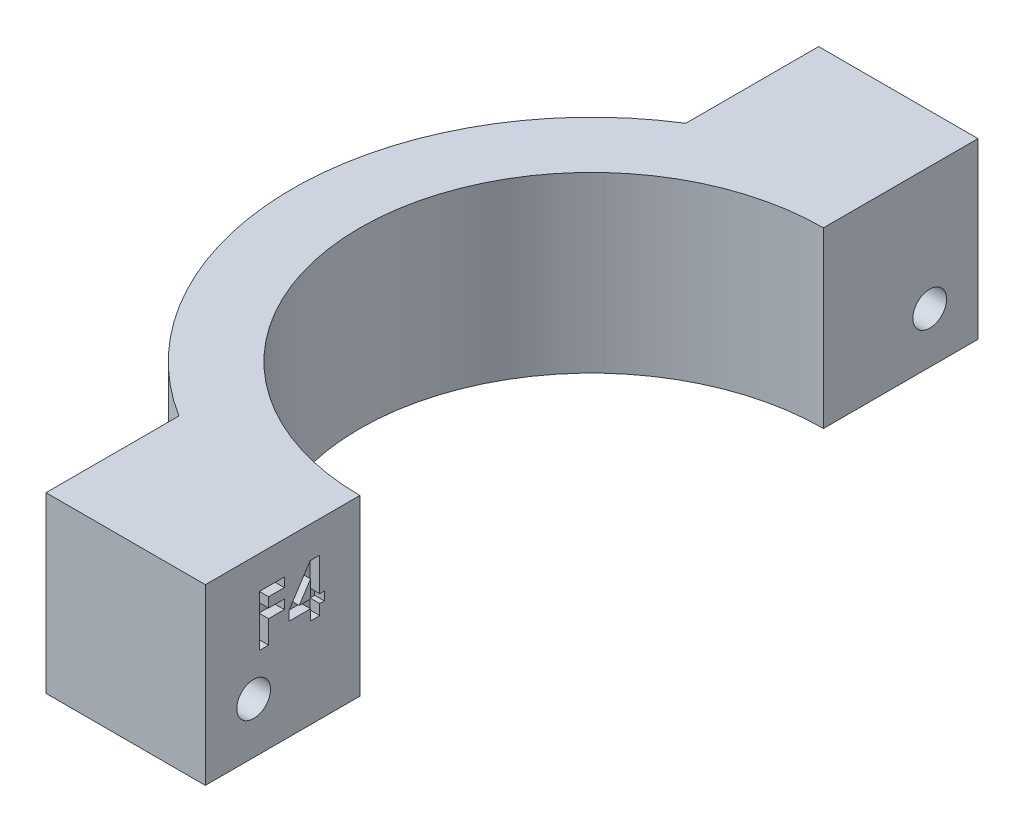
from build123d import *

# Parameters (mm, degrees)
BOSS_EXTRUDE1_DEPTH = 18
SKETCH2_R           = 1.75
CUT_EXTRUDE1_DEPTH  = 32
CUT_EXTRUDE2_DEPTH  = 1
CUT_EXTRUDE3_DEPTH  = 5


with BuildPart() as part:
    # Sketch1 → Boss-Extrude1 (new body)
    with BuildSketch(Plane(origin=(0, 0, 0), x_dir=(1, 0, 0), z_dir=(0, 1, 0))):
        with BuildLine():
            Line((-13.998275301, 32.528571429), (-30.498275301, 32.528571429))
            Line((-30.498275301, 32.528571429), (-30.498275301, 18.772618373))
            ThreePointArc((-30.498275301, 18.772618373), (-22.584151632, 22.315862806), (-13.998275301, 23.528571429))
            Line((-13.998275301, 23.528571429), (-13.998275301, 32.528571429))
        make_face()
        with BuildLine():
            ThreePointArc((-13.998275301, 23.528571429), (-22.584151632, 22.315862806), (-30.498275301, 18.772618373))
            ThreePointArc((-30.498275301, 18.772618373), (-44.998275301, -7.471428571), (-30.498275301, -33.715475515))
            ThreePointArc((-30.498275301, -33.715475515), (-22.584151632, -37.258719949), (-13.998275301, -38.471428571))
            Line((-13.998275301, -38.471428571), (-13.998275301, -31.471428571))
            ThreePointArc((-13.998275301, -31.471428571), (-37.998275301, -7.471428571), (-13.998275301, 16.528571429))
            Line((-13.998275301, 16.528571429), (-13.998275301, 23.528571429))
        make_face()
        with BuildLine():
            Line((-30.498275301, -33.715475515), (-30.498275301, -47.471428571))
            Line((-30.498275301, -47.471428571), (-13.998275301, -47.471428571))
            Line((-13.998275301, -47.471428571), (-13.998275301, -38.471428571))
            ThreePointArc((-13.998275301, -38.471428571), (-22.584151632, -37.258719949), (-30.498275301, -33.715475515))
        make_face()
    extrude(amount=BOSS_EXTRUDE1_DEPTH)

    # Sketch2 → Cut-Extrude1 (cut, through all)
    with BuildSketch(Plane(origin=(-13.998275301, 0, 0), x_dir=(0, 0, -1), z_dir=(1, 0, 0))):
        with Locations((-42.471428571, 5.25)):
            Circle(SKETCH2_R)
        with Locations((27.528571429, 5.25)):
            Circle(SKETCH2_R)
    extrude(amount=-CUT_EXTRUDE1_DEPTH, mode=Mode.SUBTRACT)

    # Sketch3 → Cut-Extrude2 (cut)
    with BuildSketch(Plane(origin=(-13.998275301, 0, 0), x_dir=(0, 0, -1), z_dir=(1, 0, 0))):
        Polygon((-41.872123333, 14.596956651), (-39.29413188, 14.596956651), (-39.29413188, 13.647170326), (-40.922337009, 13.647170326), (-40.922337009, 12.629542121), (-39.29413188, 12.629542121), (-39.29413188, 11.679755796), (-40.922337009, 11.679755796), (-40.922337009, 9.305289984), (-41.872123333, 9.305289984), align=None)
        Polygon((-36.619677754, 14.732640412), (-35.630670342, 14.732640412), (-35.630670342, 11.272704514), (-35.15577718, 11.272704514), (-35.15577718, 10.39076007), (-35.630670342, 10.39076007), (-35.630670342, 9.305289984), (-36.580456667, 9.305289984), (-36.580456667, 10.39076007), (-38.819238718, 10.39076007), (-38.819238718, 11.352206718), align=None)
        Polygon((-36.580456667, 11.272704514), (-36.580456667, 13.073694431), (-37.751789132, 11.272704514), align=None, mode=Mode.SUBTRACT)
    extrude(amount=-CUT_EXTRUDE2_DEPTH, mode=Mode.SUBTRACT)

    # Sketch4 → Cut-Extrude3 (cut)
    with BuildSketch(Plane.ZY.offset(30.498275301)):
        Polygon((-25.218846283, 3.070893971), (-24.486547677, 6.160727637), (-26.796272822, 8.339833666), (-29.838296574, 7.429106029), (-30.57059518, 4.339272363), (-28.260870035, 2.160166334), align=None)
        Polygon((44.316873767, 2.665882092), (45.632062924, 5.556143466), (43.786617729, 8.140261375), (40.625983376, 7.834117908), (39.310794219, 4.943856534), (41.156239414, 2.359738625), align=None)
    extrude(amount=-CUT_EXTRUDE3_DEPTH, mode=Mode.SUBTRACT)


solid = part.part
